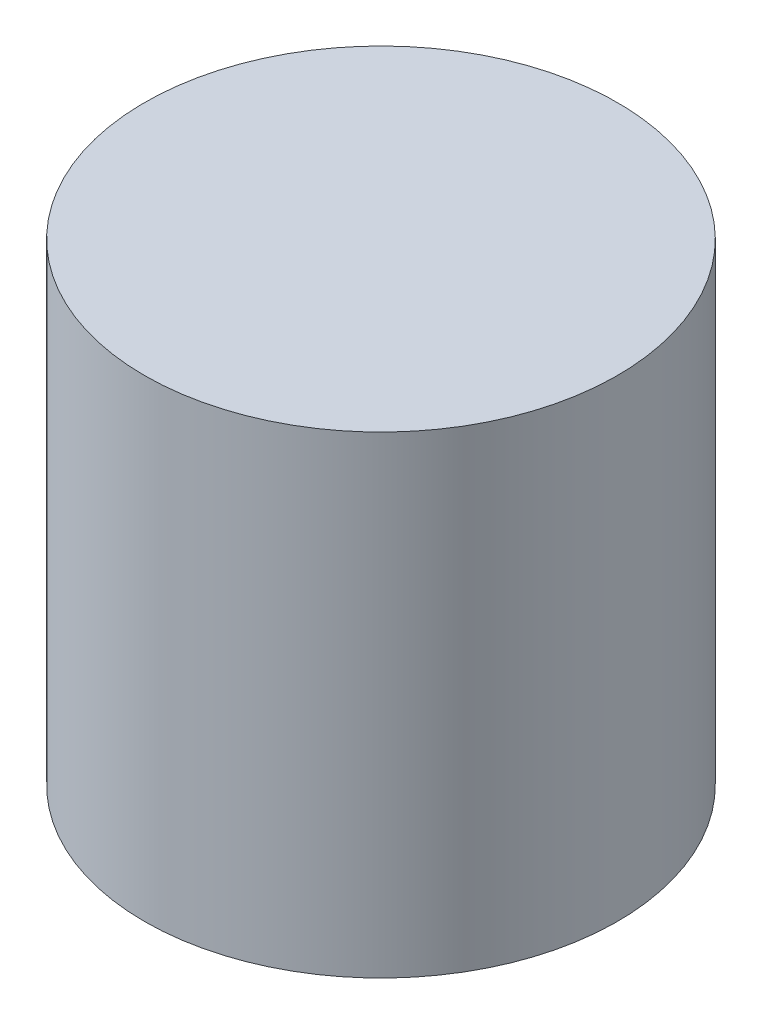
from build123d import *

# Parameters (mm, degrees)
SKETCH1_R           = 45
BOSS_EXTRUDE1_DEPTH = 90


with BuildPart() as part:
    # Sketch1 → Boss-Extrude1 (new body)
    with BuildSketch(Plane(origin=(0, 0, 0), x_dir=(1, 0, 0), z_dir=(0, 1, 0))):
        Circle(SKETCH1_R)
    extrude(amount=BOSS_EXTRUDE1_DEPTH)


solid = part.part
